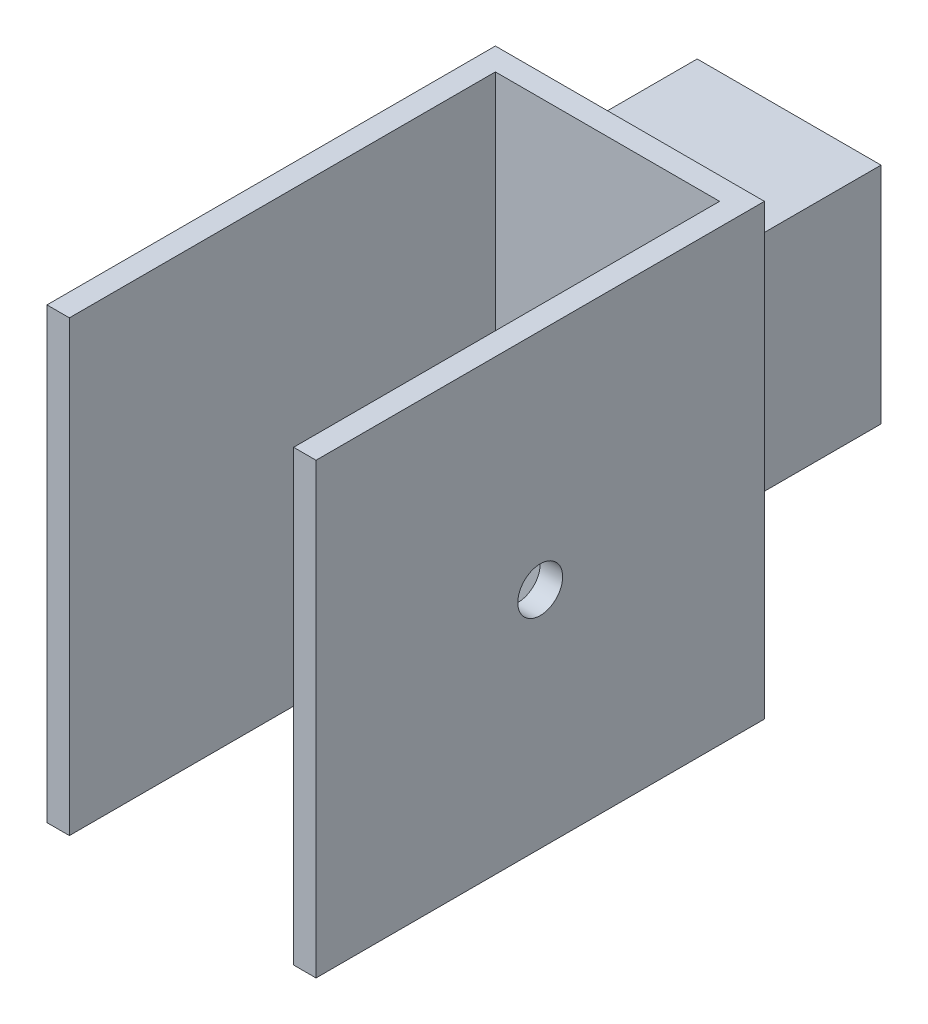
from build123d import *

# Parameters (mm, degrees)
SCHIZZO1_W                   = 60
SCHIZZO1_H                   = 100
ESTRUSIONE_ESTRUSIONE1_DEPTH = 100
SCHIZZO2_W                   = 50
SCHIZZO2_H                   = 95
TAGLIO_ESTRUSIONE1_DEPTH     = 101
SCHIZZO3_R                   = 5
TAGLIO_ESTRUSIONE2_DEPTH     = 21
SCHIZZO4_W                   = 41
SCHIZZO4_H                   = 50
ESTRUSIONE_ESTRUSIONE2_DEPTH = 45
SVUOTA1_T                    = -2


with BuildPart() as part:
    # Schizzo1 → Estrusione-Estrusione1 (new body)
    with BuildSketch(Plane.XY):
        Rectangle(SCHIZZO1_W, SCHIZZO1_H)
    extrude(amount=ESTRUSIONE_ESTRUSIONE1_DEPTH)

    # Schizzo2 → Taglio-Estrusione1 (cut, through all)
    with BuildSketch(Plane(origin=(0, 50, 0), x_dir=(1, 0, 0), z_dir=(0, 1, 0))):
        with Locations((0, -52.5)):
            Rectangle(SCHIZZO2_W, SCHIZZO2_H)
    extrude(amount=-TAGLIO_ESTRUSIONE1_DEPTH, mode=Mode.SUBTRACT)

    # Schizzo3 → Taglio-Estrusione2 (cut)
    with BuildSketch(Plane(origin=(30, 0, 0), x_dir=(0, 0, -1), z_dir=(1, 0, 0))):
        with Locations((-50, 0)):
            Circle(SCHIZZO3_R)
    extrude(amount=-TAGLIO_ESTRUSIONE2_DEPTH, mode=Mode.SUBTRACT)

    # Schizzo4 → Estrusione-Estrusione2 (add)
    with BuildSketch(Plane(origin=(0, 0, 0), x_dir=(-1, 0, 0), z_dir=(0, 0, -1))):
        with Locations((9.5, 0)):
            Rectangle(SCHIZZO4_W, SCHIZZO4_H)
    extrude(amount=ESTRUSIONE_ESTRUSIONE2_DEPTH)

    # Svuota1
    svuota1_openings = [part.faces().sort_by_distance(p)[0] for p in [
        (-9.5, 0, -45),
    ]]
    offset(amount=SVUOTA1_T, openings=svuota1_openings, kind=Kind.INTERSECTION)


solid = part.part
